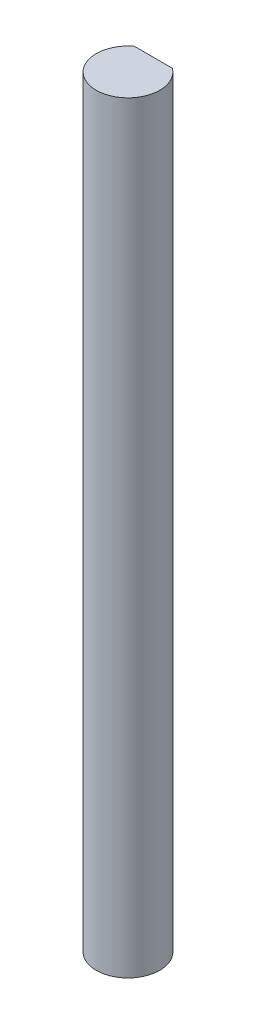
from build123d import *

# Parameters (mm, degrees)
BOSS_EXTRUDE1_DEPTH = 76.2


with BuildPart() as part:
    # Sketch1 → Boss-Extrude1 (new body)
    with BuildSketch(Plane(origin=(0, 0, 0), x_dir=(1, 0, 0), z_dir=(0, 1, 0))):
        with BuildLine():
            Line((-1.905, 2.54), (1.905, 2.54))
            ThreePointArc((1.905, 2.54), (0, -3.175), (-1.905, 2.54))
        make_face()
    extrude(amount=BOSS_EXTRUDE1_DEPTH)


solid = part.part
